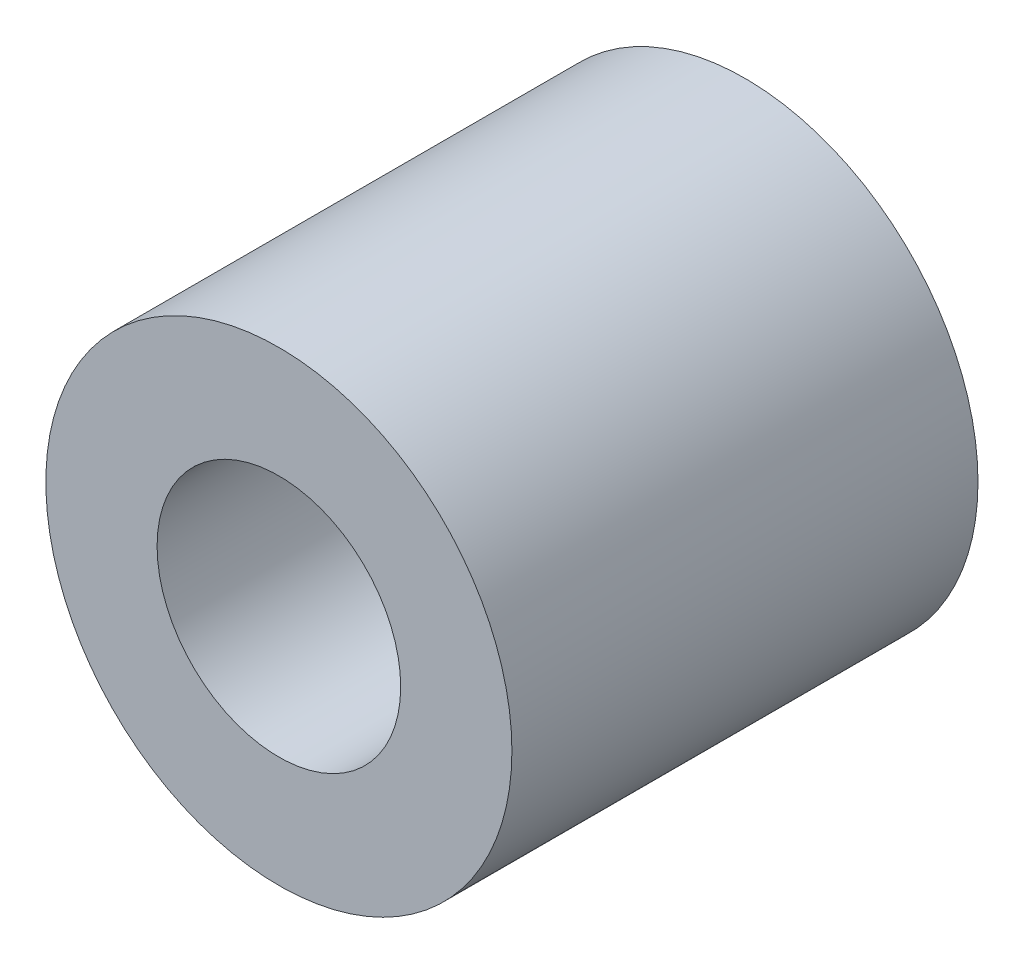
from build123d import *

# Parameters (mm, degrees)
SKETCH1_R           = 4.7625
SKETCH1_R_2         = 2.4892
BOSS_EXTRUDE1_DEPTH = 4.7625


with BuildPart() as part:
    # Sketch1 → Boss-Extrude1 (new body, symmetric)
    with BuildSketch(Plane.XY):
        Circle(SKETCH1_R)
        Circle(SKETCH1_R_2, mode=Mode.SUBTRACT)
    extrude(amount=BOSS_EXTRUDE1_DEPTH, both=True)


solid = part.part
